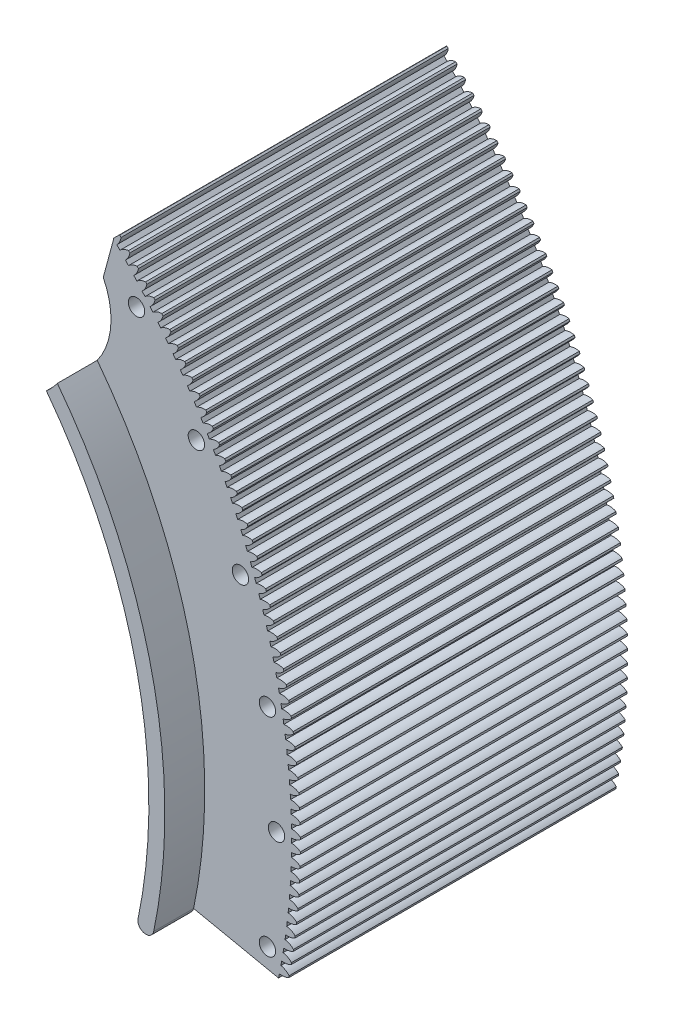
from build123d import *

# Parameters (mm, degrees)
BOSS_EXTRUDE2_DEPTH     = 15.875
SKETCH3_R               = 3.2639
BOSS_EXTRUDE3_DEPTH     = 130.175
SKETCH4_R               = 28.575
CUT_EXTRUDE1_DEPTH      = 333.857457489
CUT_EXTRUDE1_DEPTH_BACK = 333.857457489
BOSS_EXTRUDE4_DEPTH     = 130.175
CUT_EXTRUDE2_DEPTH      = 337.352349496
CIRPATTERN1_COUNT       = 310


with BuildPart() as part:
    # Sketch1 → Boss-Extrude2 (new body)
    with BuildSketch(Plane.XY):
        with BuildLine():
            ThreePointArc((160.517658678, 124.596634194), (161.078924686, 129.05154502), (165.533835512, 128.490279013))
            ThreePointArc((165.533835512, 128.490279013), (198.240785071, 67.910188), (209.55, 0))
            ThreePointArc((209.55, 0), (208.439431699, -21.545436009), (205.119498327, -42.8625))
            ThreePointArc((205.119498327, -42.8625), (201.362195322, -45.320939369), (198.903755953, -41.563636364))
            ThreePointArc((198.903755953, -41.563636364), (202.123085284, -20.892544009), (203.2, 0))
            ThreePointArc((203.2, 0), (192.233488554, 65.852303515), (160.517658678, 124.596634194))
        make_face()
    boss_extrude2 = extrude(amount=BOSS_EXTRUDE2_DEPTH)

    # Sketch3 → Boss-Extrude3 (add)
    with BuildSketch(Plane.XY.offset(15.875)):
        with BuildLine():
            Line((198.903755953, -41.563636364), (239.306081381, -50.00625))
            ThreePointArc((239.306081381, -50.00625), (238.201271239, 55.028901542), (193.122808097, 149.905325515))
            ThreePointArc((193.122808097, 149.905325515), (183.61109394, 161.41558725), (173.414436378, 172.323703769))
            Line((173.414436378, 172.323703769), (160.517658678, 124.596634194))
            ThreePointArc((160.517658678, 124.596634194), (197.985472199, 45.738307776), (198.903755953, -41.563636364))
        make_face()
        with Locations((238.125, 0)):
            Circle(SKETCH3_R, mode=Mode.SUBTRACT)
        with Locations((234.507346186, 41.349972307)):
            Circle(SKETCH3_R, mode=Mode.SUBTRACT)
        with Locations((223.764305325, 81.443546629)):
            Circle(SKETCH3_R, mode=Mode.SUBTRACT)
        with Locations((206.222299276, 119.0625)):
            Circle(SKETCH3_R, mode=Mode.SUBTRACT)
        with Locations((182.414333018, 153.063799557)):
            Circle(SKETCH3_R, mode=Mode.SUBTRACT)
        with Locations((234.507346186, -41.349972307)):
            Circle(SKETCH3_R, mode=Mode.SUBTRACT)
    extrude(amount=BOSS_EXTRUDE3_DEPTH)

    # Mirror1: Boss-Extrude2 across plane
    add(boss_extrude2.mirror(Plane(origin=(0, 0, 80.9625), x_dir=(1, 0, 0), z_dir=(0, 0, -1))))

    # Sketch4 → Cut-Extrude1 (cut, two sides)
    with BuildSketch(Plane.XY.offset(146.05)) as cut_extrude1_sk:
        with Locations((143.684097937, 143.684097937)):
            Circle(SKETCH4_R)
    extrude(amount=CUT_EXTRUDE1_DEPTH, mode=Mode.SUBTRACT)
    extrude(cut_extrude1_sk.sketch, amount=-CUT_EXTRUDE1_DEPTH_BACK, mode=Mode.SUBTRACT)

    # Sketch5 → Boss-Extrude4 (add)
    with BuildSketch(Plane.XY.offset(146.05)):
        with BuildLine():
            Line((173.132919436, 172.043957497), (175.666571915, 174.561673948))
            ThreePointArc((175.666571915, 174.561673948), (237.441667726, 70.370284406), (242.413952568, -50.655681818))
            Line((242.413952568, -50.655681818), (238.917597483, -49.925071023))
            ThreePointArc((238.917597483, -49.925071023), (234.017028288, 69.355328381), (173.132919436, 172.043957497))
        make_face()
    extrude(amount=-BOSS_EXTRUDE4_DEPTH)

    # Sketch6 → Cut-Extrude2 (cut, through all)
    with BuildSketch(Plane.XY.offset(146.05)):
        with BuildLine():
            ThreePointArc((248.427382709, 2.851742369), (246.460261142, 1.40974191), (244.076489787, 0.893440919))
            ThreePointArc((244.076489787, 0.893440919), (244.078125, 0), (244.076489787, -0.893440919))
            ThreePointArc((244.076489787, -0.893440919), (246.460261142, -1.40974191), (248.427382709, -2.851742369))
            ThreePointArc((248.427382709, -2.851742369), (248.44375, 0), (248.427382709, 2.851742369))
        make_face()
    cut_extrude2 = extrude(amount=-CUT_EXTRUDE2_DEPTH, mode=Mode.SUBTRACT)

    # CirPattern1: Cut-Extrude2 ×310 about axis
    cirpattern1_axis = Axis((0, 0, 0), (0, 0, 1))
    for i in range(1, CIRPATTERN1_COUNT):
        add(cut_extrude2.rotate(cirpattern1_axis, i * 360 / CIRPATTERN1_COUNT), mode=Mode.SUBTRACT)


solid = part.part
